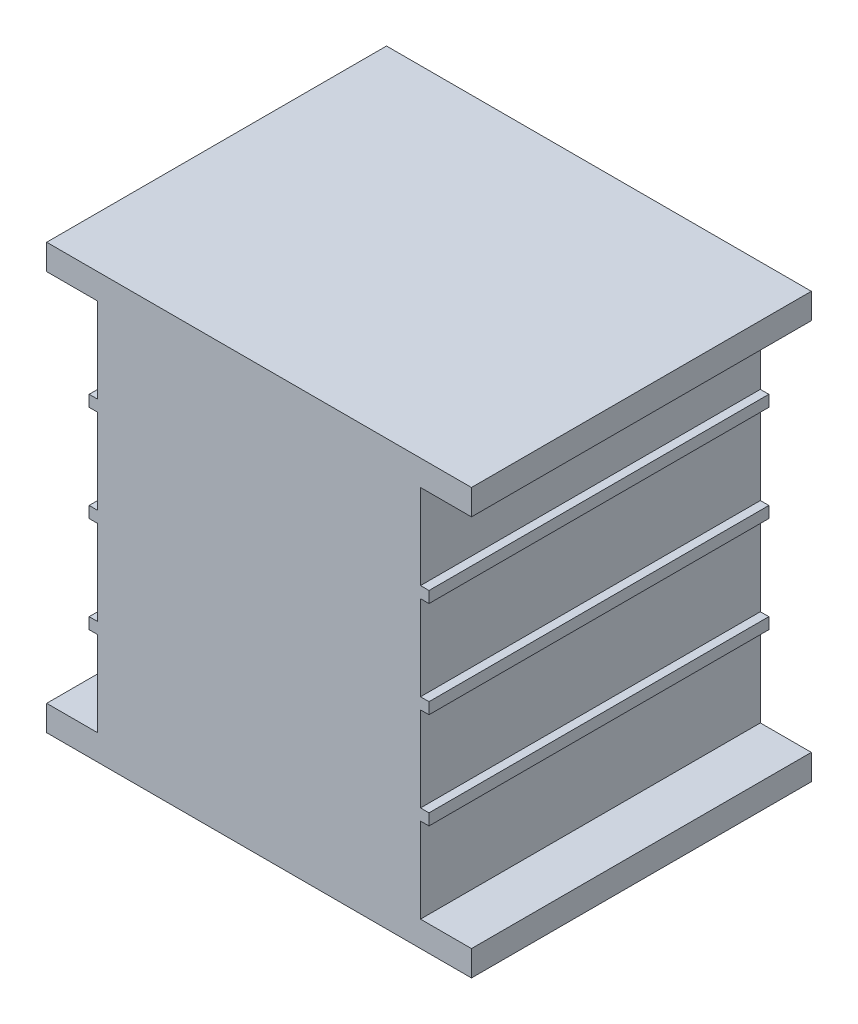
from build123d import *

# Parameters (mm, degrees)
BOSS_EXTRUDE1_DEPTH = 20


with BuildPart() as part:
    # Sketch2 → Boss-Extrude1 (new body)
    with BuildSketch(Plane.XY):
        Polygon((0, 0), (25, 0), (25, 1.5), (22, 1.5), (22, 6.5), (22.5, 6.5), (22.5, 7.166666667), (22, 7.166666667), (22, 12.166666667), (22.5, 12.166666667), (22.5, 12.833333333), (22, 12.833333333), (22, 17.833333333), (22.5, 17.833333333), (22.5, 18.5), (22, 18.5), (22, 23.5), (25, 23.5), (25, 25), (0, 25), (0, 23.5), (3, 23.5), (3, 18.5), (2.5, 18.5), (2.5, 17.833333333), (3, 17.833333333), (3, 12.833333333), (2.5, 12.833333333), (2.5, 12.166666667), (3, 12.166666667), (3, 7.166666667), (2.5, 7.166666667), (2.5, 6.5), (3, 6.5), (3, 1.5), (0, 1.5), align=None)
    extrude(amount=BOSS_EXTRUDE1_DEPTH)


solid = part.part
